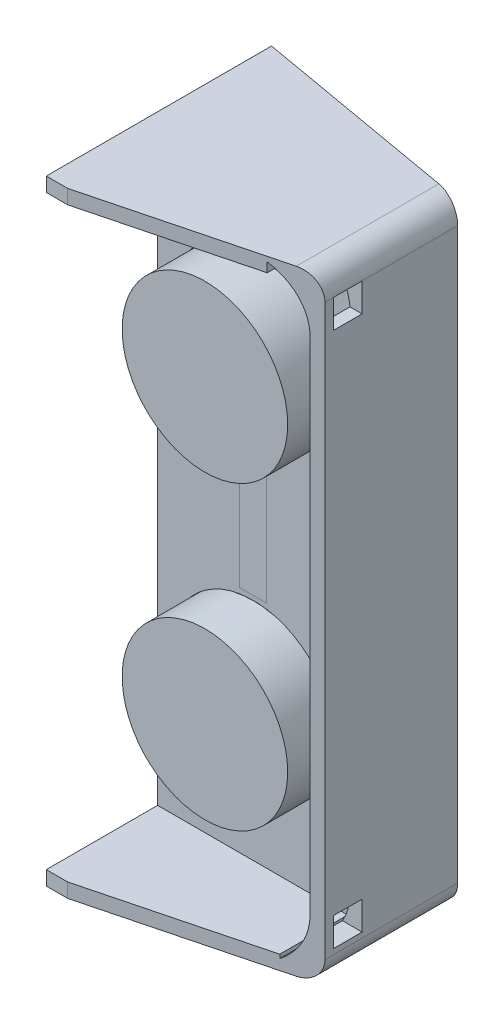
from build123d import *

# Parameters (mm, degrees)
SKETCH7_R                = 36.83
SKETCH7_R_2              = 1.905
BOSS_EXTRUDE1_DEPTH      = 6.35
SKETCH8_R                = 36.83
BOSS_EXTRUDE2_DEPTH      = 25.4
BOSS_EXTRUDE2_DEPTH_BACK = 0.000254
SKETCH9_R                = 34.925
CUT_EXTRUDE4_DEPTH       = 25.4
BOSS_EXTRUDE3_DEPTH      = 3.175
BOSS_EXTRUDE4_DEPTH      = 38.1
BOSS_EXTRUDE4_DEPTH_BACK = 40.64
CUT_EXTRUDE5_START       = -20.32
SKETCH12_W               = 34.495809925
SKETCH12_H               = 261.703089784
CUT_EXTRUDE5_DEPTH       = 48.26
SKETCH18_W               = 80.102069995
SKETCH18_H               = 6.35
SKETCH18_W_2             = 84.52860838
BOSS_EXTRUDE7_DEPTH      = 66.04
BOSS_EXTRUDE7_DEPTH_BACK = 55.88
MAIN_ANGLE_DEPTH         = 274.638700862
SKETCH19_W               = 12.7
SKETCH19_H               = 12.7
CUT_EXTRUDE8_DEPTH       = 45.72
SKETCH20_W               = 18.203212612
SKETCH20_H               = 62.726676146
CUT_EXTRUDE9_DEPTH       = 6.35
CUT_EXTRUDE9_TAPER       = 26
SKETCH23_R               = 1.905
CUT_EXTRUDE10_DEPTH      = 56.88
SKETCH24_W               = 16.196066748
SKETCH24_H               = 62.242020171
BOSS_EXTRUDE10_DEPTH     = 3.81


with BuildPart() as part:
    # Sketch7 → Boss-Extrude1 (new body)
    with BuildSketch(Plane.XY):
        with BuildLine():
            Line((117.378076693, -136.321789995), (117.378076693, 124.616910866))
            Line((117.378076693, 124.616910866), (117.378076693, 130.966910866))
            Line((117.378076693, 130.966910866), (187.228076693, 130.966910866))
            ThreePointArc((187.228076693, 130.966910866), (205.188588935, 123.527423108), (212.628076693, 105.566910866))
            Line((212.628076693, 105.566910866), (212.628076693, -117.271789995))
            ThreePointArc((212.628076693, -117.271789995), (205.188588935, -135.232302238), (187.228076693, -142.671789995))
            Line((187.228076693, -142.671789995), (117.378076693, -142.671789995))
            Line((117.378076693, -142.671789995), (117.378076693, -136.321789995))
        make_face()
        with Locations((159.923076693, 61.116910866)):
            Circle(SKETCH7_R, mode=Mode.SUBTRACT)
        with Locations((159.923076693, -72.821789995)):
            Circle(SKETCH7_R, mode=Mode.SUBTRACT)
        with Locations((198.520756421, 117.007578537)):
            Circle(SKETCH7_R_2, mode=Mode.SUBTRACT)
        with Locations((198.520756421, -128.598951794)):
            Circle(SKETCH7_R_2, mode=Mode.SUBTRACT)
    extrude(amount=BOSS_EXTRUDE1_DEPTH)

    # Sketch8 → Boss-Extrude2 (add, two sides)
    with BuildSketch(Plane.XY.offset(2.54)) as boss_extrude2_sk:
        with Locations((160.02, 60.978458264)):
            Circle(SKETCH8_R)
        with Locations((160.02, -72.960242597)):
            Circle(SKETCH8_R)
    extrude(amount=BOSS_EXTRUDE2_DEPTH)
    extrude(boss_extrude2_sk.sketch, amount=-BOSS_EXTRUDE2_DEPTH_BACK)

    # Sketch9 → Cut-Extrude4 (cut)
    with BuildSketch(Plane(origin=(0, 0, 0), x_dir=(-1, 0, 0), z_dir=(0, 0, -1))):
        with Locations((-160.02, 60.978458264)):
            Circle(SKETCH9_R)
        with Locations((-160.02, -72.960242597)):
            Circle(SKETCH9_R)
    extrude(amount=-CUT_EXTRUDE4_DEPTH, mode=Mode.SUBTRACT)

    # Sketch10 → Boss-Extrude3 (add)
    with BuildSketch(Plane.XY.offset(6.35)):
        with BuildLine():
            Line((187.228076693, 130.966910866), (187.228076693, 105.566910866))
            Line((187.228076693, 105.566910866), (212.628076693, 105.566910866))
            ThreePointArc((212.628076693, 105.566910866), (205.188588935, 123.527423108), (187.228076693, 130.966910866))
        make_face()
        with BuildLine():
            Line((212.628076693, -117.271789995), (187.228076693, -117.271789995))
            Line((187.228076693, -117.271789995), (187.228076693, -142.671789995))
            ThreePointArc((187.228076693, -142.671789995), (205.188588935, -135.232302238), (212.628076693, -117.271789995))
        make_face()
    extrude(amount=-BOSS_EXTRUDE3_DEPTH)

    # Sketch11 → Boss-Extrude4 (add, two sides)
    with BuildSketch(Plane(origin=(0, 0, 0), x_dir=(-1, 0, 0), z_dir=(0, 0, -1))) as boss_extrude4_sk:
        with BuildLine():
            Line((-217.892216682, -132.511789995), (-217.892216682, 120.806910866))
            ThreePointArc((-217.892216682, 120.806910866), (-214.916421579, 127.991115763), (-207.732216682, 130.966910866))
            Line((-207.732216682, 130.966910866), (-187.228076693, 130.966910866))
            ThreePointArc((-187.228076693, 130.966910866), (-205.188588935, 123.527423108), (-212.628076693, 105.566910866))
            Line((-212.628076693, 105.566910866), (-212.628076693, -117.271789995))
            ThreePointArc((-212.628076693, -117.271789995), (-205.188588935, -135.232302238), (-187.228076693, -142.671789995))
            Line((-187.228076693, -142.671789995), (-207.732216682, -142.671789995))
            ThreePointArc((-207.732216682, -142.671789995), (-214.916421579, -139.695994892), (-217.892216682, -132.511789995))
        make_face()
    extrude(amount=BOSS_EXTRUDE4_DEPTH)
    extrude(boss_extrude4_sk.sketch, amount=-BOSS_EXTRUDE4_DEPTH_BACK)

    # Sketch12 → Cut-Extrude5 (cut)
    with BuildSketch(Plane.XY.offset(6.35).offset(CUT_EXTRUDE5_START)):
        with Locations((195.299001462, -6.234634026)):
            Rectangle(SKETCH12_W, SKETCH12_H)
    extrude(amount=-CUT_EXTRUDE5_DEPTH, mode=Mode.SUBTRACT)

    # Sketch18 → Boss-Extrude7 (add, two sides)
    with BuildSketch(Plane(origin=(0, 0, 0), x_dir=(-1, 0, 0), z_dir=(0, 0, -1))) as boss_extrude7_sk:
        with Locations((-157.429111691, 127.791910866)):
            Rectangle(SKETCH18_W, SKETCH18_H)
        with Locations((-159.642380883, -139.496789995)):
            Rectangle(SKETCH18_W_2, SKETCH18_H)
    extrude(amount=BOSS_EXTRUDE7_DEPTH)
    extrude(boss_extrude7_sk.sketch, amount=-BOSS_EXTRUDE7_DEPTH_BACK)

    # Sketch16 → main angle (cut, through all)
    with BuildSketch(Plane(origin=(0, 130.966910866, 0), x_dir=(1, 0, 0), z_dir=(0, 1, 0))):
        Polygon((217.892216682, 26.67), (-101.016881875, 82.73406518), (217.892216682, 82.73406518), align=None)
        Polygon((217.892216682, -32.396277701), (47.589100189, -76.347646381), (217.892216682, -67.47666805), align=None)
    extrude(amount=-MAIN_ANGLE_DEPTH, mode=Mode.SUBTRACT)

    # Sketch19 → Cut-Extrude8 (cut)
    with BuildSketch(Plane(origin=(217.892216682, 0, 0), x_dir=(0, 0, -1), z_dir=(1, 0, 0))):
        with Locations((-22.215809399, -123.786574298)):
            Rectangle(SKETCH19_W, SKETCH19_H)
        with Locations((-22.215809399, 114.456910866)):
            Rectangle(SKETCH19_W, SKETCH19_H)
    extrude(amount=-CUT_EXTRUDE8_DEPTH, mode=Mode.SUBTRACT)

    # Sketch20 → Cut-Extrude9 (cut)
    with BuildSketch(Plane(origin=(0, 0, 0), x_dir=(-1, 0, 0), z_dir=(0, 0, -1))):
        with Locations((-159.923076693, -5.934095423)):
            Rectangle(SKETCH20_W, SKETCH20_H)
    extrude(amount=-CUT_EXTRUDE9_DEPTH, taper=CUT_EXTRUDE9_TAPER, mode=Mode.SUBTRACT)

    # Sketch23 → Cut-Extrude10 (cut, through all)
    with BuildSketch(Plane(origin=(0, 0, 0), x_dir=(-1, 0, 0), z_dir=(0, 0, -1))):
        with Locations((-198.520756421, 117.007578537)):
            Circle(SKETCH23_R)
        with Locations((-198.520756421, -128.598951794)):
            Circle(SKETCH23_R)
    extrude(amount=-CUT_EXTRUDE10_DEPTH, mode=Mode.SUBTRACT)

    # Sketch24 → Boss-Extrude10 (add)
    with BuildSketch(Plane(origin=(0, 0, 2.539746), x_dir=(-1, 0, 0), z_dir=(0, 0, -1))):
        with Locations((-160.078035159, -5.897511229)):
            Rectangle(SKETCH24_W, SKETCH24_H)
    extrude(amount=-BOSS_EXTRUDE10_DEPTH)


solid = part.part
